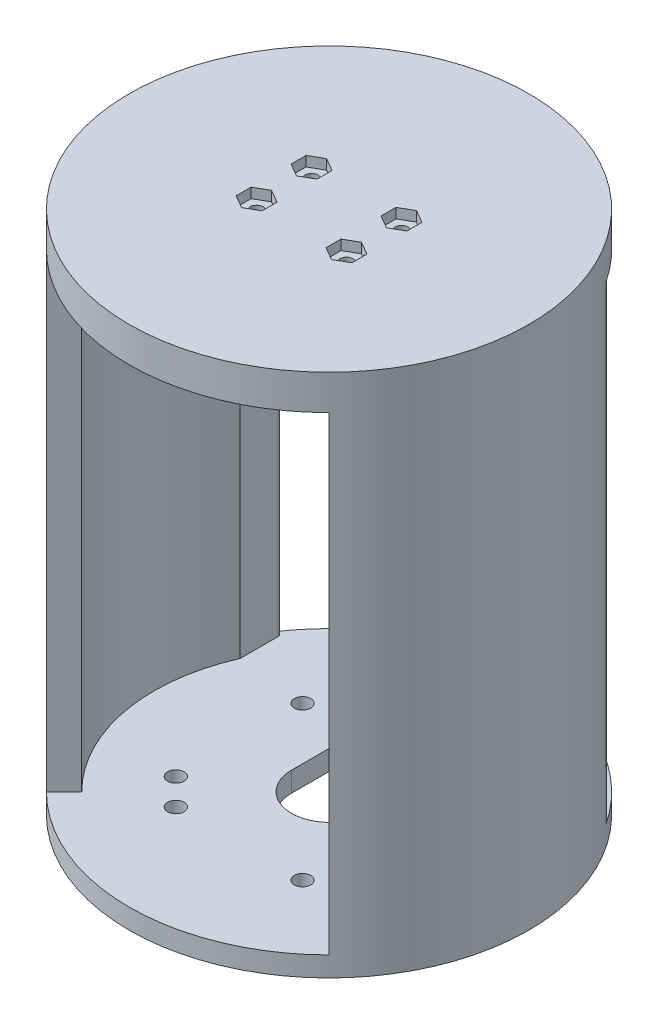
from build123d import *

# Parameters (mm, degrees)
SKETCH1_R           = 1.65
BOSS_EXTRUDE1_DEPTH = 4
BOSS_EXTRUDE2_DEPTH = 94
SKETCH3_R           = 40
BOSS_EXTRUDE3_DEPTH = 7
SKETCH4_R           = 1.3
CUT_EXTRUDE1_DEPTH  = 22
SKETCH5_W           = 23
SKETCH5_H           = 29
CUT_EXTRUDE2_DEPTH  = 1.6
SKETCH6_W           = 7.5
SKETCH6_H           = 2.1
SKETCH6_W_2         = 20
SKETCH6_H_2         = 4.5
CUT_EXTRUDE3_DEPTH  = 4
CUT_EXTRUDE4_DEPTH  = 2
BOSS_EXTRUDE4_DEPTH = 4
CUT_EXTRUDE5_DEPTH  = 4


with BuildPart() as part:
    # Sketch1 → Boss-Extrude1 (new body)
    with BuildSketch(Plane(origin=(0, 0, 0), x_dir=(1, 0, 0), z_dir=(0, 1, 0))):
        with BuildLine():
            Line((-7.5, 0), (-7.5, -39.290584114))
            ThreePointArc((-7.5, -39.290584114), (0, 40), (7.5, -39.290584114))
            Line((7.5, -39.290584114), (7.5, 0))
            ThreePointArc((7.5, 0), (0, 7.5), (-7.5, 0))
        make_face()
        with Locations((-17.977187763, 12.681510956)):
            Circle(SKETCH1_R, mode=Mode.SUBTRACT)
        with Locations((-12.681510956, 17.977187763)):
            Circle(SKETCH1_R, mode=Mode.SUBTRACT)
        with Locations((12.681510956, 17.977187763)):
            Circle(SKETCH1_R, mode=Mode.SUBTRACT)
        with Locations((17.977187763, 12.681510956)):
            Circle(SKETCH1_R, mode=Mode.SUBTRACT)
        with Locations((17.977187763, -12.681510956)):
            Circle(SKETCH1_R, mode=Mode.SUBTRACT)
        with Locations((12.681510956, -17.977187763)):
            Circle(SKETCH1_R, mode=Mode.SUBTRACT)
        with Locations((-12.681510956, -17.977187763)):
            Circle(SKETCH1_R, mode=Mode.SUBTRACT)
        with Locations((-17.977187763, -12.681510956)):
            Circle(SKETCH1_R, mode=Mode.SUBTRACT)
    extrude(amount=BOSS_EXTRUDE1_DEPTH)

    # Sketch2 → Boss-Extrude2 (add)
    with BuildSketch(Plane(origin=(0, 4, 0), x_dir=(1, 0, 0), z_dir=(0, 1, 0))):
        with BuildLine():
            Line((-24.748737342, -24.748737342), (-28.284271247, -28.284271247))
            ThreePointArc((-28.284271247, -28.284271247), (-39.805294785, -3.941891309), (-33.282442748, 22.187361374))
            ThreePointArc((-33.282442748, 22.187361374), (-32.497157603, 22.469048938), (-32, 21.79908255))
            Line((-32, 21.79908255), (-32, 14.177446879))
            ThreePointArc((-32, 14.177446879), (-34.408091373, -6.409621521), (-24.748737342, -24.748737342))
        make_face()
        with BuildLine():
            Line((24.748737342, -24.748737342), (28.284271247, -28.284271247))
            ThreePointArc((28.284271247, -28.284271247), (39.805294785, -3.941891309), (33.282442748, 22.187361374))
            ThreePointArc((33.282442748, 22.187361374), (32.497157603, 22.469048938), (32, 21.79908255))
            Line((32, 21.79908255), (32, 14.177446879))
            ThreePointArc((32, 14.177446879), (34.408091373, -6.409621521), (24.748737342, -24.748737342))
        make_face()
    extrude(amount=BOSS_EXTRUDE2_DEPTH)

    # Sketch3 → Boss-Extrude3 (add)
    with BuildSketch(Plane(origin=(0, 98, 0), x_dir=(1, 0, 0), z_dir=(0, 1, 0))):
        Circle(SKETCH3_R)
    extrude(amount=BOSS_EXTRUDE3_DEPTH)

    # Sketch4 → Cut-Extrude1 (cut)
    with BuildSketch(Plane.XZ.offset(-98)):
        with Locations((9, -5.5)):
            Circle(SKETCH4_R)
        with Locations((-9, -5.5)):
            Circle(SKETCH4_R)
        with Locations((9, 5.5)):
            Circle(SKETCH4_R)
        with Locations((-9, 5.5)):
            Circle(SKETCH4_R)
    extrude(amount=-CUT_EXTRUDE1_DEPTH, mode=Mode.SUBTRACT)

    # Sketch5 → Cut-Extrude2 (cut)
    with BuildSketch(Plane.XZ.offset(-98)):
        with Locations((0, 6.5)):
            Rectangle(SKETCH5_W, SKETCH5_H)
    extrude(amount=-CUT_EXTRUDE2_DEPTH, mode=Mode.SUBTRACT)

    # Sketch6 → Cut-Extrude3 (cut)
    with BuildSketch(Plane.XZ.offset(-99.6)):
        with Locations((0.75, 9.95)):
            Rectangle(SKETCH6_W, SKETCH6_H)
        with Locations((0, 16.75)):
            Rectangle(SKETCH6_W_2, SKETCH6_H_2)
    extrude(amount=-CUT_EXTRUDE3_DEPTH, mode=Mode.SUBTRACT)

    # Sketch7 → Cut-Extrude4 (cut)
    with BuildSketch(Plane(origin=(0, 105, 0), x_dir=(1, 0, 0), z_dir=(0, 1, 0))):
        Polygon((9, -8.5), (11.598076211, -7), (11.598076211, -4), (9, -2.5), (6.401923789, -4), (6.401923789, -7), align=None)
        Polygon((-9, 2.5), (-6.401923789, 4), (-6.401923789, 7), (-9, 8.5), (-11.598076211, 7), (-11.598076211, 4), align=None)
        Polygon((-9, -8.5), (-6.401923789, -7), (-6.401923789, -4), (-9, -2.5), (-11.598076211, -4), (-11.598076211, -7), align=None)
        Polygon((9, 2.5), (11.598076211, 4), (11.598076211, 7), (9, 8.5), (6.401923789, 7), (6.401923789, 4), align=None)
    extrude(amount=-CUT_EXTRUDE4_DEPTH, mode=Mode.SUBTRACT)

    # Sketch8 → Boss-Extrude4 (add)
    with BuildSketch(Plane.XZ):
        with BuildLine():
            Line((-7.935549944, -8.30342312), (8.145763187, -8.30342312))
            Line((8.145763187, -8.30342312), (8.145763187, 39.161799526))
            ThreePointArc((8.145763187, 39.161799526), (0.107296793, 39.999856092), (-7.935549944, 39.204936514))
            Line((-7.935549944, 39.204936514), (-7.935549944, -8.30342312))
        make_face()
    extrude(amount=-BOSS_EXTRUDE4_DEPTH)

    # Sketch9 → Cut-Extrude5 (cut)
    with BuildSketch(Plane.XZ):
        with BuildLine():
            Line((-7.5, 0), (-7.5, -42.568181818))
            Line((-7.5, -42.568181818), (7.5, -42.568181818))
            Line((7.5, -42.568181818), (7.5, 0))
            ThreePointArc((7.5, 0), (0, 7.5), (-7.5, 0))
        make_face()
    extrude(amount=-CUT_EXTRUDE5_DEPTH, mode=Mode.SUBTRACT)


solid = part.part
